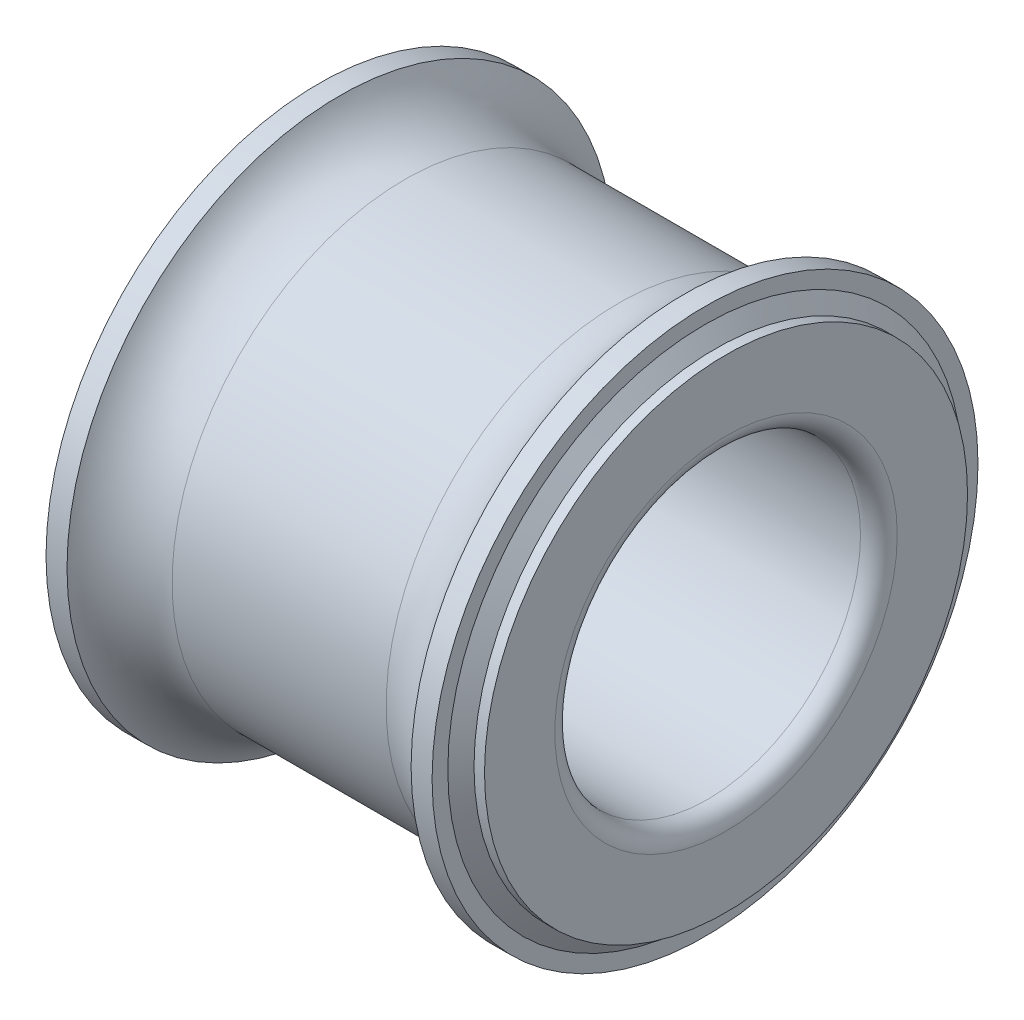
from build123d import *


with BuildPart() as part:
    # Sketch1 → Revolve1 (revolve)
    with BuildSketch(Plane.XY):
        with BuildLine():
            Line((0.6, 5), (13.4, 5))
            ThreePointArc((13.4, 5), (13.824264069, 5.175735931), (14, 5.6))
            Line((14, 5.6), (14, 8.728))
            ThreePointArc((14, 8.728), (13.941421356, 8.869421356), (13.8, 8.928))
            Line((13.8, 8.928), (12.627143625, 8.928))
            ThreePointArc((12.627143625, 8.928), (11.749083664, 7.971770723), (10.5, 7.618))
            Line((10.5, 7.618), (3.5, 7.618))
            ThreePointArc((3.5, 7.618), (2.250916336, 7.971770723), (1.372856375, 8.928))
            Line((1.372856375, 8.928), (0.2, 8.928))
            ThreePointArc((0.2, 8.928), (0.058578644, 8.869421356), (0, 8.728))
            Line((0, 8.728), (0, 5.6))
            ThreePointArc((0, 5.6), (0.175735931, 5.175735931), (0.6, 5))
        make_face()
    revolve(axis=Axis((13.4, 0, 0), (-1, 0, 0)))

    # Sketch2 → Cut-Revolve1 (revolve, cut)
    with BuildSketch(Plane.XY):
        Polygon((0, 7.9), (0.343214094, 7.9), (0.686428188, 8.414), (0.686428188, 8.928), (13.313571812, 8.928), (13.313571812, 8.414), (13.656785906, 7.9), (14, 7.9), (14, 11.828), (0, 11.828), align=None)
    revolve(axis=Axis((14, 0, 0), (-1, 0, 0)), mode=Mode.SUBTRACT)


solid = part.part
